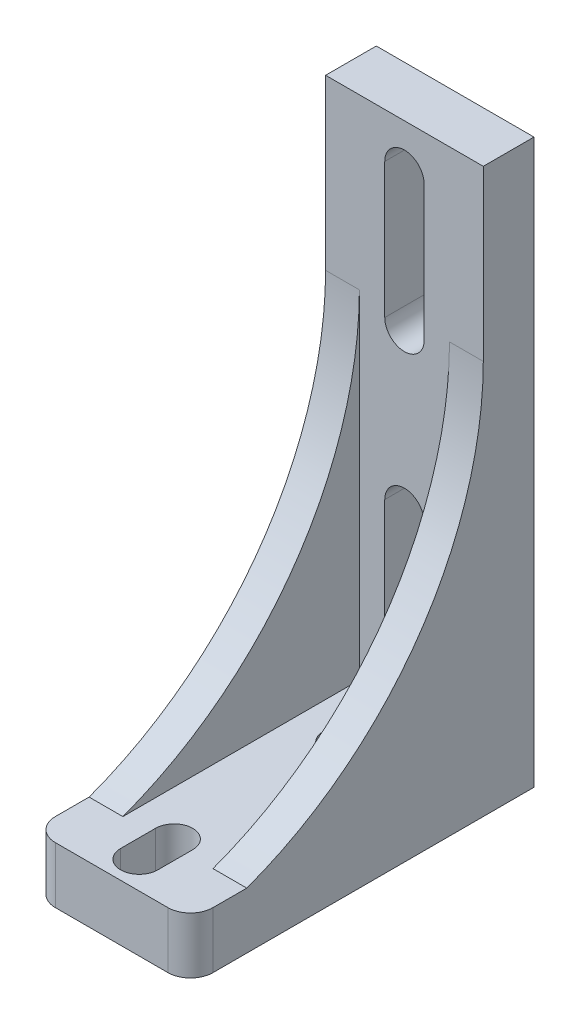
from build123d import *

# Parameters (mm, degrees)
CROQUIS2_W              = 14
CROQUIS2_H              = 31
CROQUIS2_R              = 1.55
SALIENTE_EXTRUIR1_DEPTH = 50
CROQUIS3_W              = 26
CROQUIS3_H              = 45
CORTAR_EXTRUIR1_DEPTH   = 14
CORTAR_EXTRUIR2_DEPTH   = 5
SALIENTE_EXTRUIR3_DEPTH = 14
CROQUIS7_OUTSIDE_W      = 28.094
CROQUIS7_OUTSIDE_H      = 45.094
CORTAR_EXTRUIR5_DEPTH   = 45
REDONDEO1_R             = 2
CROQUIS8_W              = 14
CROQUIS8_H              = 0.5
CORTAR_EXTRUIR6_DEPTH   = 50
CORTAR_EXTRUIR7_DEPTH   = 5


with BuildPart() as part:
    # Croquis2 → Saliente-Extruir1 (new body)
    with BuildSketch(Plane(origin=(0, 0, 0), x_dir=(1, 0, 0), z_dir=(0, 1, 0))):
        with Locations((7, 15.5)):
            Rectangle(CROQUIS2_W, CROQUIS2_H)
        with Locations((7, 22)):
            Circle(CROQUIS2_R, mode=Mode.SUBTRACT)
        with Locations((7, 4)):
            Circle(CROQUIS2_R, mode=Mode.SUBTRACT)
    extrude(amount=SALIENTE_EXTRUIR1_DEPTH)

    # Croquis3 → Cortar-Extruir1 (cut)
    with BuildSketch(Plane.ZY):
        with Locations((-13, 27.5)):
            Rectangle(CROQUIS3_W, CROQUIS3_H)
    extrude(amount=-CORTAR_EXTRUIR1_DEPTH, mode=Mode.SUBTRACT)

    # Croquis4 → Cortar-Extruir2 (cut)
    with BuildSketch(Plane(origin=(0, 0, -31), x_dir=(-1, 0, 0), z_dir=(0, 0, -1))):
        with BuildLine():
            Line((-8.75, 8), (-8.75, 20))
            ThreePointArc((-8.75, 20), (-7, 21.75), (-5.25, 20))
            Line((-5.25, 20), (-5.25, 8))
            ThreePointArc((-5.25, 8), (-7, 6.25), (-8.75, 8))
        make_face()
        with BuildLine():
            Line((-8.75, 34), (-8.75, 46))
            ThreePointArc((-8.75, 46), (-7, 47.75), (-5.25, 46))
            Line((-5.25, 46), (-5.25, 34))
            ThreePointArc((-5.25, 34), (-7, 32.25), (-8.75, 34))
        make_face()
    extrude(amount=-CORTAR_EXTRUIR2_DEPTH, mode=Mode.SUBTRACT)

    # Croquis6 → Saliente-Extruir3 (add)
    with BuildSketch(Plane.ZY):
        with BuildLine():
            Line((-26, 5), (-26, 35))
            ThreePointArc((-26, 35), (-20.21590319, 16.698867767), (-5, 5))
            Line((-5, 5), (-26, 5))
        make_face()
    extrude(amount=-SALIENTE_EXTRUIR3_DEPTH)

    # Croquis7 outside → Cortar-Extruir5 (cut)
    with BuildSketch(Plane(origin=(0, 50, 0), x_dir=(1, 0, 0), z_dir=(0, 1, 0))):
        with Locations((7, 15.5)):
            Rectangle(CROQUIS7_OUTSIDE_W, CROQUIS7_OUTSIDE_H)
        Polygon((0, 26), (0, 0), (3, 0), (3, 26), (11, 26), (11, 0), (14, 0), (14, 26), (14, 31), (0, 31), align=None, mode=Mode.SUBTRACT)
    extrude(amount=-CORTAR_EXTRUIR5_DEPTH, mode=Mode.SUBTRACT)

    # Redondeo1
    redondeo1_edges = [part.edges().sort_by_distance(p)[0] for p in [
        (14, 2.5, 0),
        (0, 2.5, 0),
    ]]
    fillet(redondeo1_edges, radius=REDONDEO1_R)

    # Croquis8 → Cortar-Extruir6 (cut)
    with BuildSketch(Plane(origin=(0, 50, 0), x_dir=(1, 0, 0), z_dir=(0, 1, 0))):
        with Locations((7, 30.75)):
            Rectangle(CROQUIS8_W, CROQUIS8_H)
    extrude(amount=-CORTAR_EXTRUIR6_DEPTH, mode=Mode.SUBTRACT)

    # Croquis9 → Cortar-Extruir7 (cut)
    with BuildSketch(Plane.XZ):
        with BuildLine():
            Line((8.65, -20.45), (8.65, -23.55))
            ThreePointArc((8.65, -23.55), (7, -25.2), (5.35, -23.55))
            Line((5.35, -23.55), (5.35, -20.45))
            ThreePointArc((5.35, -20.45), (7, -18.8), (8.65, -20.45))
        make_face()
        with BuildLine():
            Line((8.65, -2.45), (8.65, -5.55))
            ThreePointArc((8.65, -5.55), (7, -7.2), (5.35, -5.55))
            Line((5.35, -5.55), (5.35, -2.45))
            ThreePointArc((5.35, -2.45), (7, -0.8), (8.65, -2.45))
        make_face()
    extrude(amount=-CORTAR_EXTRUIR7_DEPTH, mode=Mode.SUBTRACT)


solid = part.part
